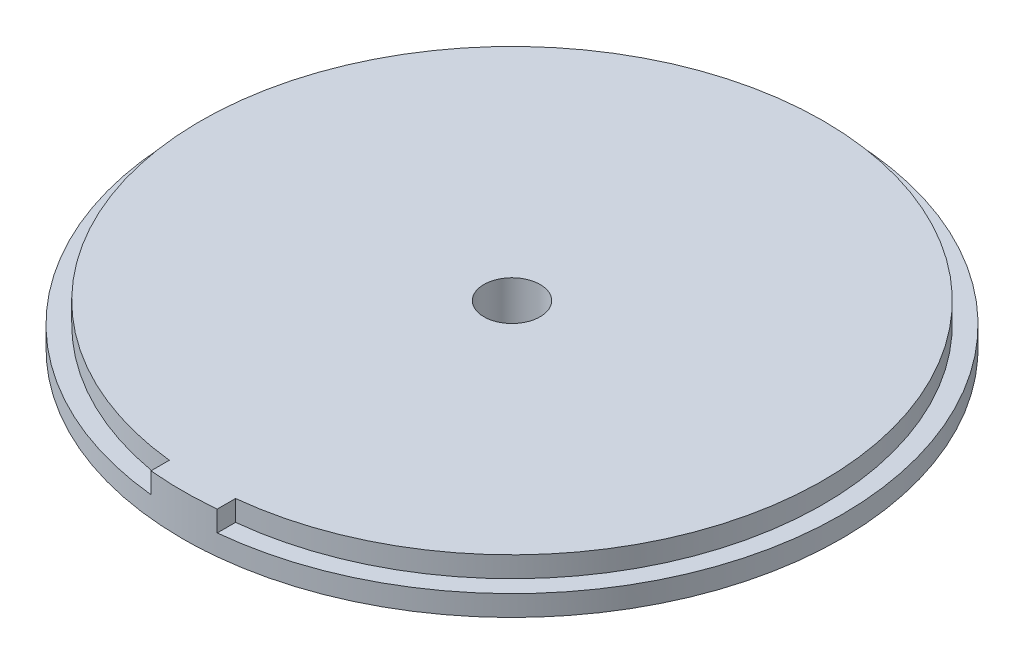
from build123d import *

# Parameters (mm, degrees)
SKETCH1_R                 = 25.273
BOSS_EXTRUDE1_DEPTH       = 1.5875
SKETCH2_R                 = 23.876
BOSS_EXTRUDE2_DEPTH       = 1.5875
BOSS_EXTRUDE3_DEPTH       = 1.5875
F_8_CLEARANCE_HOLE1_D     = 4.3053
F_8_CLEARANCE_HOLE1_DEPTH = 3.175


with BuildPart() as part:
    # Sketch1 → Boss-Extrude1 (new body)
    with BuildSketch(Plane(origin=(0, 0, 0), x_dir=(1, 0, 0), z_dir=(0, 1, 0))):
        Circle(SKETCH1_R)
    extrude(amount=BOSS_EXTRUDE1_DEPTH)

    # Sketch2 → Boss-Extrude2 (add)
    with BuildSketch(Plane(origin=(0, 1.5875, 0), x_dir=(1, 0, 0), z_dir=(0, 1, 0))):
        Circle(SKETCH2_R)
    extrude(amount=BOSS_EXTRUDE2_DEPTH)

    # Sketch3 → Boss-Extrude3 (add)
    with BuildSketch(Plane(origin=(0, 1.5875, 0), x_dir=(1, 0, 0), z_dir=(0, 1, 0))):
        with BuildLine():
            Line((-2.54, -25.14503786), (-2.54, -23.740509177))
            ThreePointArc((-2.54, -23.740509177), (0, -23.876), (2.54, -23.740509177))
            Line((2.54, -23.740509177), (2.54, -25.14503786))
            ThreePointArc((2.54, -25.14503786), (0, -25.273), (-2.54, -25.14503786))
        make_face()
    extrude(amount=BOSS_EXTRUDE3_DEPTH)

    # #8 Clearance Hole1
    with Locations(Plane.ZX.offset(3.175)):
        with Locations((0, 0)):
            Hole(F_8_CLEARANCE_HOLE1_D / 2, depth=F_8_CLEARANCE_HOLE1_DEPTH)


solid = part.part
